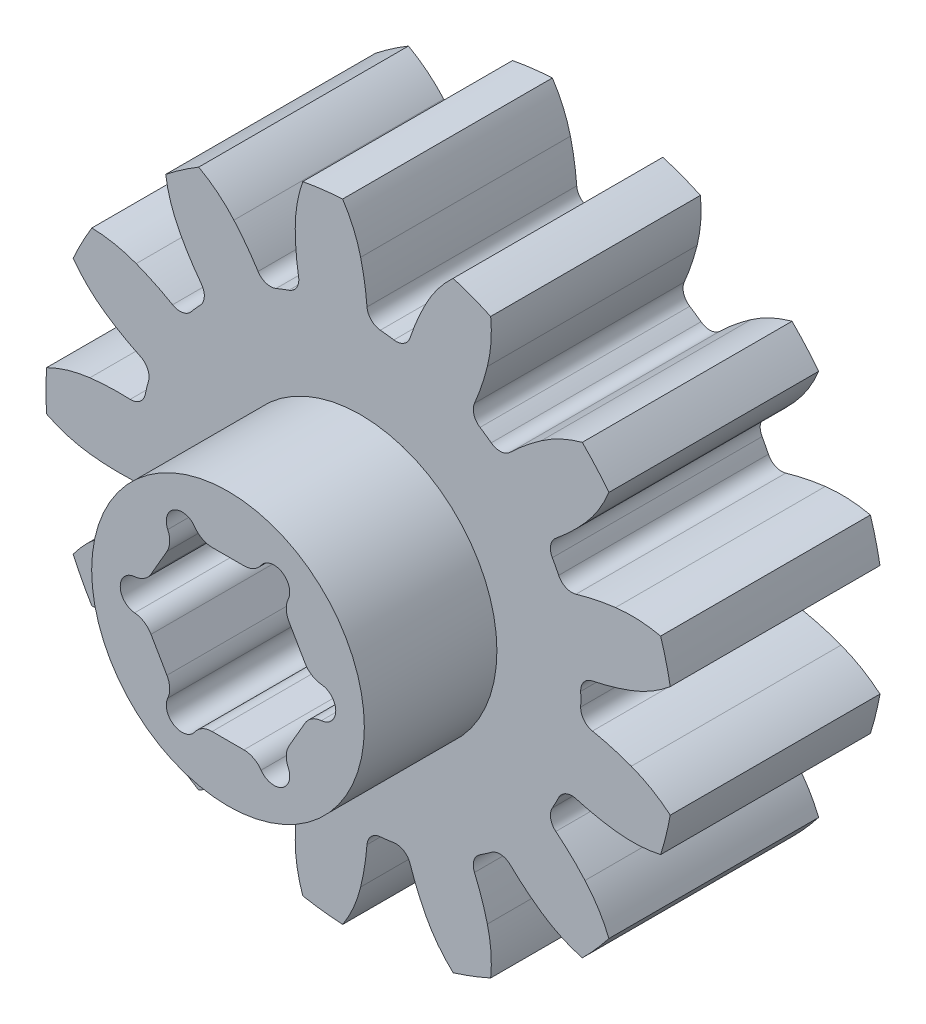
from build123d import *

# Parameters (mm, degrees)
SKETCH1_R           = 9.525
ROUND_STOCK_DEPTH   = 3.175
SINGLE_TOOTH_DEPTH  = 15.892070037
TOOTH_PATTERN_COUNT = 13
CUT_EXTRUDE1_DEPTH  = 15.882187212
SKETCH8_R           = 4.1275
BOSS_EXTRUDE1_DEPTH = 4.0132
CUT_EXTRUDE2_DEPTH  = 3.302
FILLET1_R           = 0.635
SKETCH10_R          = 0.47625
CUT_EXTRUDE3_DEPTH  = 17.986845218
FILLET2_R           = 0.635


with BuildPart() as part:
    # Sketch1 → Round Stock (new, symmetric)
    with BuildSketch(Plane.XY):
        Circle(SKETCH1_R)
    extrude(amount=ROUND_STOCK_DEPTH, both=True)

    # Sketch2 → Single Tooth (cut, through all)
    with BuildSketch(Plane.XY.offset(3.175)):
        with BuildLine():
            ThreePointArc((-8.699219347, -3.879330837), (-9.248220811, -2.279481702), (-9.505591122, -0.607751944))
            ThreePointArc((-9.505591122, -0.607751944), (-8.866874127, -0.859264513), (-8.194501154, -0.997585))
            ThreePointArc((-8.194501154, -0.997585), (-7.585039492, -1.044554082), (-6.973773022, -1.042846396))
            ThreePointArc((-6.973773022, -1.042846396), (-6.682727126, -1.135452938), (-6.520145475, -1.394008333))
            ThreePointArc((-6.520145475, -1.394008333), (-6.473754568, -1.595637192), (-6.421130074, -1.795729609))
            ThreePointArc((-6.421130074, -1.795729609), (-6.444932293, -2.100224502), (-6.659604229, -2.317479295))
            ThreePointArc((-6.659604229, -2.317479295), (-7.201647409, -2.600036906), (-7.71947129, -2.92485692))
            ThreePointArc((-7.71947129, -2.92485692), (-8.250547255, -3.35980093), (-8.699219347, -3.879330837))
        make_face()
    single_tooth = extrude(amount=-SINGLE_TOOTH_DEPTH, mode=Mode.SUBTRACT)

    # Tooth Pattern: Single Tooth ×13 about axis
    tooth_pattern_axis = Axis((0, 0, 50), (0, 0, -1))
    for i in range(1, TOOTH_PATTERN_COUNT):
        add(single_tooth.rotate(tooth_pattern_axis, i * 360 / TOOTH_PATTERN_COUNT), mode=Mode.SUBTRACT)

    # Sketch7 → Cut-Extrude1 (cut, through all)
    with BuildSketch(Plane(origin=(0, 0, -3.175), x_dir=(-1, 0, 0), z_dir=(0, 0, -1))):
        Polygon((1.3931462, -2.413), (2.786292399, 0), (1.3931462, 2.413), (-1.3931462, 2.413), (-2.786292399, 0), (-1.3931462, -2.413), align=None)
    extrude(amount=-CUT_EXTRUDE1_DEPTH, mode=Mode.SUBTRACT)

    # Sketch8 → Boss-Extrude1 (add)
    with BuildSketch(Plane.XY.offset(3.175)):
        Circle(SKETCH8_R)
        Polygon((-1.3931462, -2.413), (1.3931462, -2.413), (2.786292399, 0), (1.3931462, 2.413), (-1.3931462, 2.413), (-2.786292399, 0), align=None, mode=Mode.SUBTRACT)
    extrude(amount=BOSS_EXTRUDE1_DEPTH)

    # Sketch9 → Cut-Extrude2 (cut)
    with BuildSketch(Plane(origin=(0, 0, -3.175), x_dir=(-1, 0, 0), z_dir=(0, 0, -1))):
        Polygon((2.492998462, -4.318), (4.985996925, 0), (2.492998462, 4.318), (-2.492998462, 4.318), (-4.985996925, 0), (-2.492998462, -4.318), align=None)
    extrude(amount=-CUT_EXTRUDE2_DEPTH, mode=Mode.SUBTRACT)

    # Fillet1
    fillet1_edges = [part.edges().sort_by_distance(p)[0] for p in [
        (4.985996925, 0, -1.524),
        (2.492998462, -4.318, -1.524),
        (-2.492998462, -4.318, -1.524),
        (-4.985996925, 0, -1.524),
        (-2.492998462, 4.318, -1.524),
        (2.492998462, 4.318, -1.524),
    ]]
    fillet(fillet1_edges, radius=FILLET1_R)

    # Sketch10 → Cut-Extrude3 (cut, through all)
    with BuildSketch(Plane.XY.offset(7.1882)):
        with Locations((-1.3931462, 2.413)):
            Circle(SKETCH10_R)
        with Locations((1.3931462, 2.413)):
            Circle(SKETCH10_R)
        with Locations((2.786292399, 0)):
            Circle(SKETCH10_R)
        with Locations((1.3931462, -2.413)):
            Circle(SKETCH10_R)
        with Locations((-1.3931462, -2.413)):
            Circle(SKETCH10_R)
        with Locations((-2.786292399, 0)):
            Circle(SKETCH10_R)
    extrude(amount=-CUT_EXTRUDE3_DEPTH, mode=Mode.SUBTRACT)

    # Fillet2
    fillet2_edges = [part.edges().sort_by_distance(p)[0] for p in [
        (0.9168962, -2.413, 3.6576),
        (-0.9168962, -2.413, 3.6576),
        (-1.6312712, -2.000555401, 3.6576),
        (-2.548167399, -0.412444599, 3.6576),
        (-2.548167399, 0.412444599, 3.6576),
        (-1.6312712, 2.000555401, 3.6576),
        (-0.9168962, 2.413, 3.6576),
        (0.9168962, 2.413, 3.6576),
        (1.6312712, 2.000555401, 3.6576),
        (2.548167399, 0.412444599, 3.6576),
        (2.548167399, -0.412444599, 3.6576),
        (1.6312712, -2.000555401, 3.6576),
    ]]
    fillet(fillet2_edges, radius=FILLET2_R)


solid = part.part
